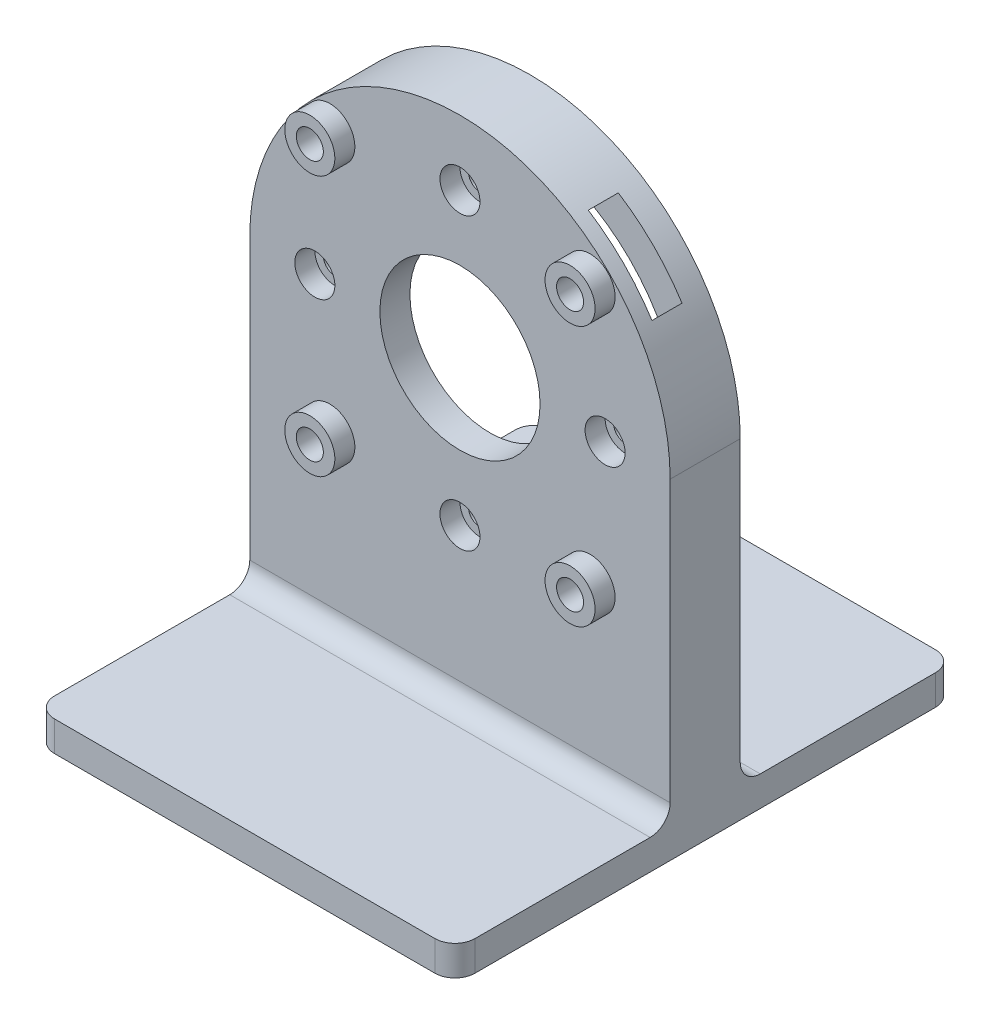
from build123d import *

# Parameters (mm, degrees)
SKETCH1_R           = 8
BOSS_EXTRUDE1_DEPTH = 7
SKETCH2_R           = 17.65
CUT_EXTRUDE1_DEPTH  = 4
CUT_EXTRUDE2_REACH  = 57.597
SKETCH4_R           = 1.15
SKETCH5_R           = 2
CUT_EXTRUDE3_DEPTH  = 2
SKETCH6_R           = 2.5
SKETCH6_R_2         = 1.35
BOSS_EXTRUDE2_DEPTH = 2
CUT_EXTRUDE4_START  = -2
SKETCH6_2_R         = 1.35
CUT_EXTRUDE4_DEPTH  = 2
CIRPATTERN3_COUNT   = 4
SKETCH7_W           = 42
SKETCH7_H           = 50
BOSS_EXTRUDE3_DEPTH = 3
FILLET1_R           = 2
CUT_EXTRUDE5_REACH  = 61.24
SKETCH8_W           = 9
SKETCH8_H           = 3


with BuildPart() as part:
    # Sketch1 → Boss-Extrude1 (new body)
    with BuildSketch(Plane.XY):
        with BuildLine():
            Line((-21, 0), (21, 0))
            Line((21, 0), (21, 30))
            ThreePointArc((21, 30), (0, 51), (-21, 30))
            Line((-21, 30), (-21, 0))
        make_face()
        with Locations((0, 30)):
            Circle(SKETCH1_R, mode=Mode.SUBTRACT)
    extrude(amount=BOSS_EXTRUDE1_DEPTH)

    # Sketch2 → Cut-Extrude1 (cut)
    with BuildSketch(Plane(origin=(0, 0, 0), x_dir=(-1, 0, 0), z_dir=(0, 0, -1))):
        with Locations((0, 30)):
            Circle(SKETCH2_R)
    extrude(amount=-CUT_EXTRUDE1_DEPTH, mode=Mode.SUBTRACT)

    # Sketch4 → Cut-Extrude2 (cut, up to next)
    with BuildSketch(Plane.XY.offset(7), mode=Mode.PRIVATE) as cut_extrude2_sk1:
        with Locations((0, 44.5)):
            Circle(SKETCH4_R)
    cut_extrude2_tool1 = extrude(cut_extrude2_sk1.sketch, amount=-CUT_EXTRUDE2_REACH, mode=Mode.PRIVATE) & part.part
    cut_extrude2 = cut_extrude2_tool1.solids().sort_by_distance((0, 44.5, 7))[0]
    add(cut_extrude2, mode=Mode.SUBTRACT)

    # Sketch5 → Cut-Extrude3 (cut)
    with BuildSketch(Plane.XY.offset(7)):
        with Locations((0, 44.5)):
            Circle(SKETCH5_R)
    cut_extrude3 = extrude(amount=-CUT_EXTRUDE3_DEPTH, mode=Mode.SUBTRACT)

    # Sketch6 → Boss-Extrude2 (add)
    with BuildSketch(Plane.XY.offset(7)):
        with Locations((-13, 43)):
            Circle(SKETCH6_R)
        with Locations((-13, 43)):
            Circle(SKETCH6_R_2, mode=Mode.SUBTRACT)
    boss_extrude2 = extrude(amount=BOSS_EXTRUDE2_DEPTH)

    # Sketch6_2 → Cut-Extrude4 (cut)
    with BuildSketch(Plane.XY.offset(7).offset(CUT_EXTRUDE4_START)):
        with Locations((-13, 43)):
            Circle(SKETCH6_2_R)
    cut_extrude4 = extrude(amount=CUT_EXTRUDE4_DEPTH, mode=Mode.SUBTRACT)

    # CirPattern3: Cut-Extrude2, Cut-Extrude3, Boss-Extrude2, Cut-Extrude4 ×4 about axis
    cirpattern3_axis = Axis((0, 30, 7), (0, 0, -1))
    add([cut_extrude2.rotate(cirpattern3_axis, i * 360 / CIRPATTERN3_COUNT) for i in range(1, CIRPATTERN3_COUNT)], mode=Mode.SUBTRACT)
    add([cut_extrude3.rotate(cirpattern3_axis, i * 360 / CIRPATTERN3_COUNT) for i in range(1, CIRPATTERN3_COUNT)], mode=Mode.SUBTRACT)
    add([boss_extrude2.rotate(cirpattern3_axis, i * 360 / CIRPATTERN3_COUNT) for i in range(1, CIRPATTERN3_COUNT)])
    add([cut_extrude4.rotate(cirpattern3_axis, i * 360 / CIRPATTERN3_COUNT) for i in range(1, CIRPATTERN3_COUNT)], mode=Mode.SUBTRACT)

    # Sketch7 → Boss-Extrude3 (add)
    with BuildSketch(Plane.XZ):
        with Locations((0, 3.5)):
            Rectangle(SKETCH7_W, SKETCH7_H)
    extrude(amount=BOSS_EXTRUDE3_DEPTH)

    # Fillet1
    fillet1_edges = [part.edges().sort_by_distance(p)[0] for p in [
        (0, 0, 7),
        (0, 0, 0),
        (21, -1.5, -21.5),
        (-21, -1.5, -21.5),
        (21, -1.5, 28.5),
        (-21, -1.5, 28.5),
    ]]
    fillet(fillet1_edges, radius=FILLET1_R)

    # Sketch8 → Cut-Extrude5 (cut, up to next)
    with BuildSketch(Plane(origin=(22.25, 22.25, 0), x_dir=(0.7071067811865513, -0.7071067811865437, 0), z_dir=(0.7071067811865437, 0.7071067811865513, 0)), mode=Mode.PRIVATE) as cut_extrude5_sk1:
        with Locations((-21.213203436, -4)):
            Rectangle(SKETCH8_W, SKETCH8_H)
    cut_extrude5_tool1 = extrude(cut_extrude5_sk1.sketch, amount=CUT_EXTRUDE5_REACH, mode=Mode.PRIVATE) & part.part
    add(cut_extrude5_tool1.solids().sort_by_distance((7.25, 37.25, 4))[0], mode=Mode.SUBTRACT)


solid = part.part
